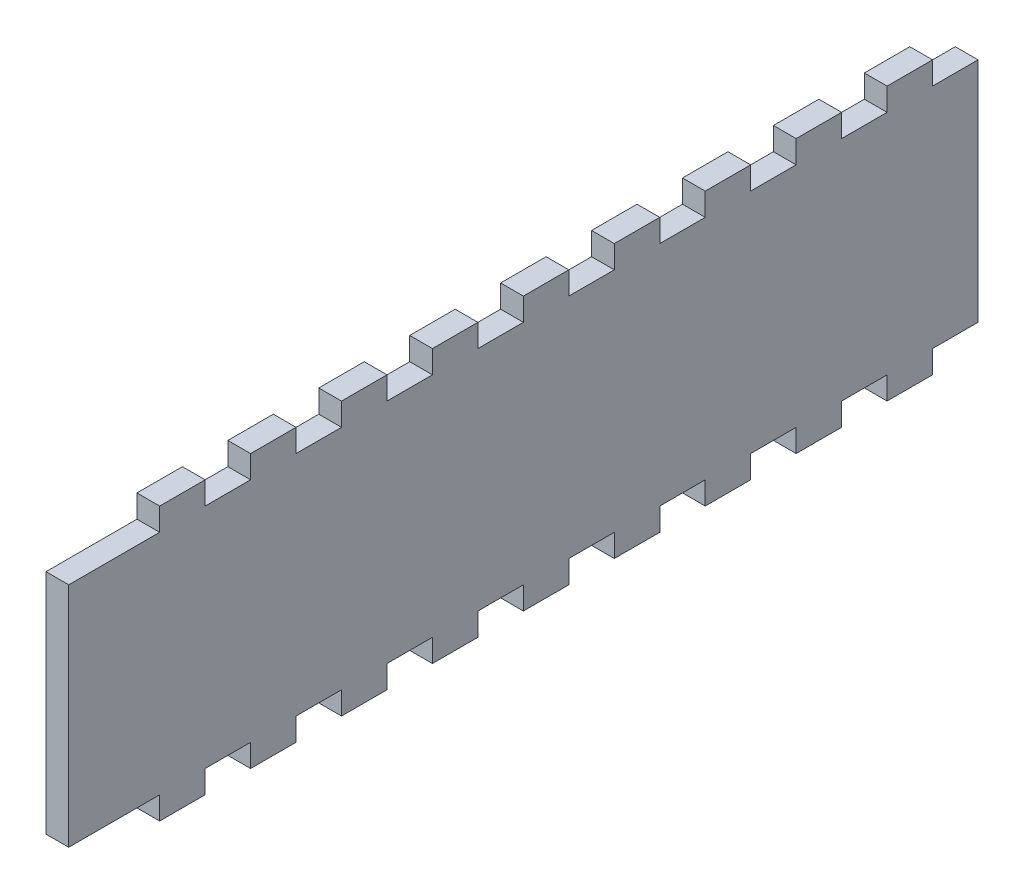
from build123d import *

# Parameters (mm, degrees)
BOSS_EXTRUDE1_DEPTH = 5


with BuildPart() as part:
    # Sketch1 → Boss-Extrude1 (new body)
    with BuildSketch(Plane(origin=(0, 0, 0), x_dir=(0, 0, -1), z_dir=(1, 0, 0))):
        Polygon((40, 50), (40, 55), (50, 55), (50, 50), (60, 50), (60, 55), (70, 55), (70, 50), (80, 50), (80, 55), (90, 55), (90, 50), (100, 50), (100, 55), (110, 55), (110, 50), (120, 50), (120, 55), (130, 55), (130, 50), (140, 50), (140, 55), (150, 55), (150, 50), (160, 50), (160, 55), (170, 55), (170, 50), (180, 50), (180, 55), (190, 55), (190, 50), (200, 50), (200, 0), (190, 0), (190, -5), (180, -5), (180, 0), (170, 0), (170, -5), (160, -5), (160, 0), (150, 0), (150, -5), (140, -5), (140, 0), (130, 0), (130, -5), (120, -5), (120, 0), (110, 0), (110, -5), (100, -5), (100, 0), (90, 0), (90, -5), (80, -5), (80, 0), (70, 0), (70, -5), (60, -5), (60, 0), (50, 0), (50, -5), (40, -5), (40, 0), (30, 0), (30, -5), (20, -5), (20, 0), (0, 0), (0, 50), (20, 50), (20, 55), (30, 55), (30, 50), align=None)
    extrude(amount=BOSS_EXTRUDE1_DEPTH)


solid = part.part
